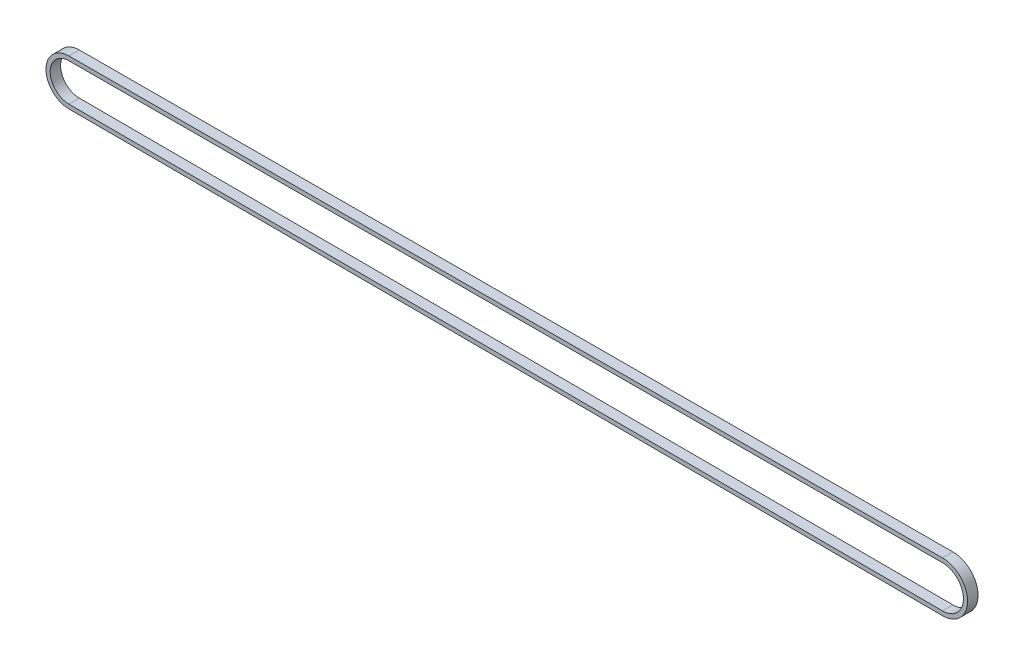
from build123d import *

# Parameters (mm, degrees)
EXTRUDE_THIN1_DEPTH = 5


with BuildPart() as part:
    # Sketch2 → Extrude-Thin1 (new body)
    with BuildSketch(Plane.XY):
        with BuildLine():
            Line((-419.026252983, 10.999968672), (-0.028639618, 11.999965824))
            ThreePointArc((-0.028639618, 11.999965824), (12, 0), (-0.028639618, -11.999965824))
            Line((-0.028639618, -11.999965824), (-419.026252983, -10.999968672))
            ThreePointArc((-419.026252983, -10.999968672), (-430, 0), (-419.026252983, 10.999968672))
        make_face()
        with BuildLine():
            Line((-419.021479714, 8.999974368), (-0.023866348, 9.99997152))
            ThreePointArc((-0.023866348, 9.99997152), (10, 0), (-0.023866348, -9.99997152))
            Line((-0.023866348, -9.99997152), (-419.021479714, -8.999974368))
            ThreePointArc((-419.021479714, -8.999974368), (-428, 0), (-419.021479714, 8.999974368))
        make_face(mode=Mode.SUBTRACT)
    extrude(amount=-EXTRUDE_THIN1_DEPTH)


solid = part.part
